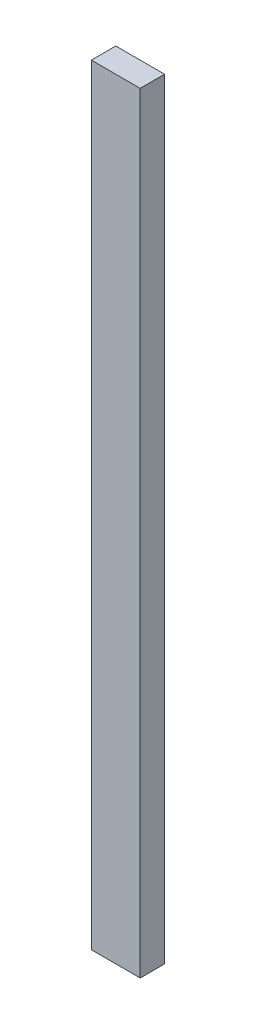
from build123d import *

# Parameters (mm, degrees)
SKETCH1_W           = 12.7
SKETCH1_H           = 200.152
BOSS_EXTRUDE1_DEPTH = 6.35


with BuildPart() as part:
    # Sketch1 → Boss-Extrude1 (new body)
    with BuildSketch(Plane.XY):
        Rectangle(SKETCH1_W, SKETCH1_H)
    extrude(amount=BOSS_EXTRUDE1_DEPTH)


solid = part.part
